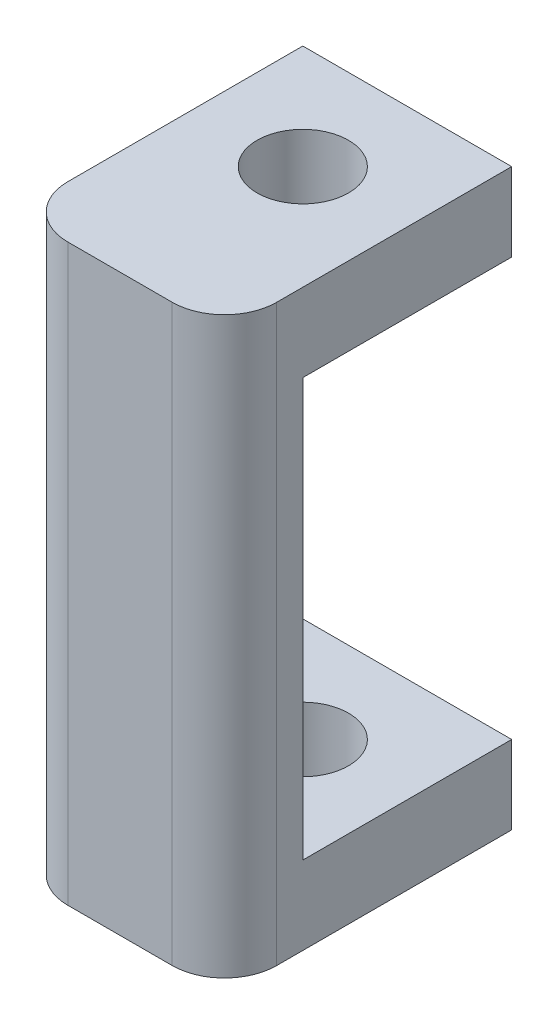
from build123d import *

# Parameters (mm, degrees)
SKETCH_1_W      = 8
SKETCH_1_H      = 8
SKETCH_1_R      = 1.75
EXTRUDE_1_DEPTH = 3
EXTRUDE_2_DEPTH = 16
SKETCH_3_R      = 1.75
EXTRUDE_3_DEPTH = 3


with BuildPart() as part:
    # 草图1 → 凸台-拉伸1 (new body)
    with BuildSketch(Plane(origin=(0, 0, 0), x_dir=(1, 0, 0), z_dir=(0, 1, 0))):
        with Locations((4, -4)):
            Rectangle(SKETCH_1_W, SKETCH_1_H)
        with Locations((4, -4)):
            Circle(SKETCH_1_R, mode=Mode.SUBTRACT)
        with BuildLine():
            Line((8, -8), (0, -8))
            Line((0, -8), (0, -9))
            ThreePointArc((0, -9), (0.585786438, -10.414213562), (2, -11))
            Line((2, -11), (6, -11))
            ThreePointArc((6, -11), (7.414213562, -10.414213562), (8, -9))
            Line((8, -9), (8, -8))
        make_face()
    extrude(amount=EXTRUDE_1_DEPTH)

    # 草图2 → 凸台-拉伸2 (add)
    with BuildSketch(Plane(origin=(0, 3, 0), x_dir=(1, 0, 0), z_dir=(0, 1, 0))):
        with BuildLine():
            Line((8, -8), (0, -8))
            Line((0, -8), (0, -9))
            ThreePointArc((0, -9), (0.585786438, -10.414213562), (2, -11))
            Line((2, -11), (6, -11))
            ThreePointArc((6, -11), (7.414213562, -10.414213562), (8, -9))
            Line((8, -9), (8, -8))
        make_face()
    extrude(amount=EXTRUDE_2_DEPTH)

    # 草图3 → 凸台-拉伸3 (add)
    with BuildSketch(Plane(origin=(0, 19, 0), x_dir=(1, 0, 0), z_dir=(0, 1, 0))):
        with BuildLine():
            Line((8, -9), (8, -8))
            Line((8, -8), (8, 0))
            Line((8, 0), (0, 0))
            Line((0, 0), (0, -8))
            Line((0, -8), (0, -9))
            ThreePointArc((0, -9), (0.585786438, -10.414213562), (2, -11))
            Line((2, -11), (6, -11))
            ThreePointArc((6, -11), (7.414213562, -10.414213562), (8, -9))
        make_face()
        with Locations((4, -4)):
            Circle(SKETCH_3_R, mode=Mode.SUBTRACT)
    extrude(amount=EXTRUDE_3_DEPTH)


solid = part.part
